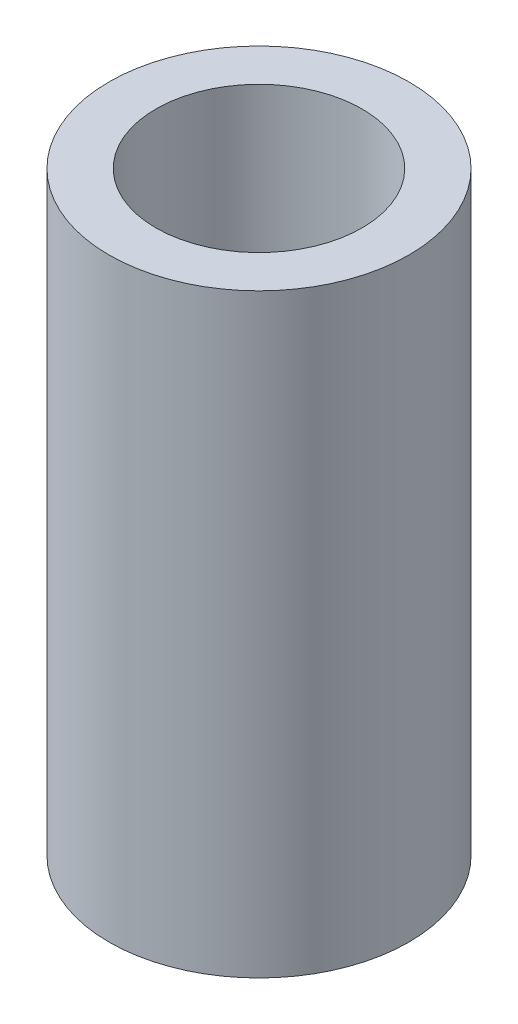
from build123d import *

# Parameters (mm, degrees)
SKETCH1_R           = 3.2
SKETCH1_R_2         = 2.2
BOSS_EXTRUDE1_DEPTH = 12.7


with BuildPart() as part:
    # Sketch1 → Boss-Extrude1 (new body)
    with BuildSketch(Plane(origin=(0, 0, 0), x_dir=(1, 0, 0), z_dir=(0, 1, 0))):
        Circle(SKETCH1_R)
        Circle(SKETCH1_R_2, mode=Mode.SUBTRACT)
    extrude(amount=BOSS_EXTRUDE1_DEPTH)


solid = part.part
